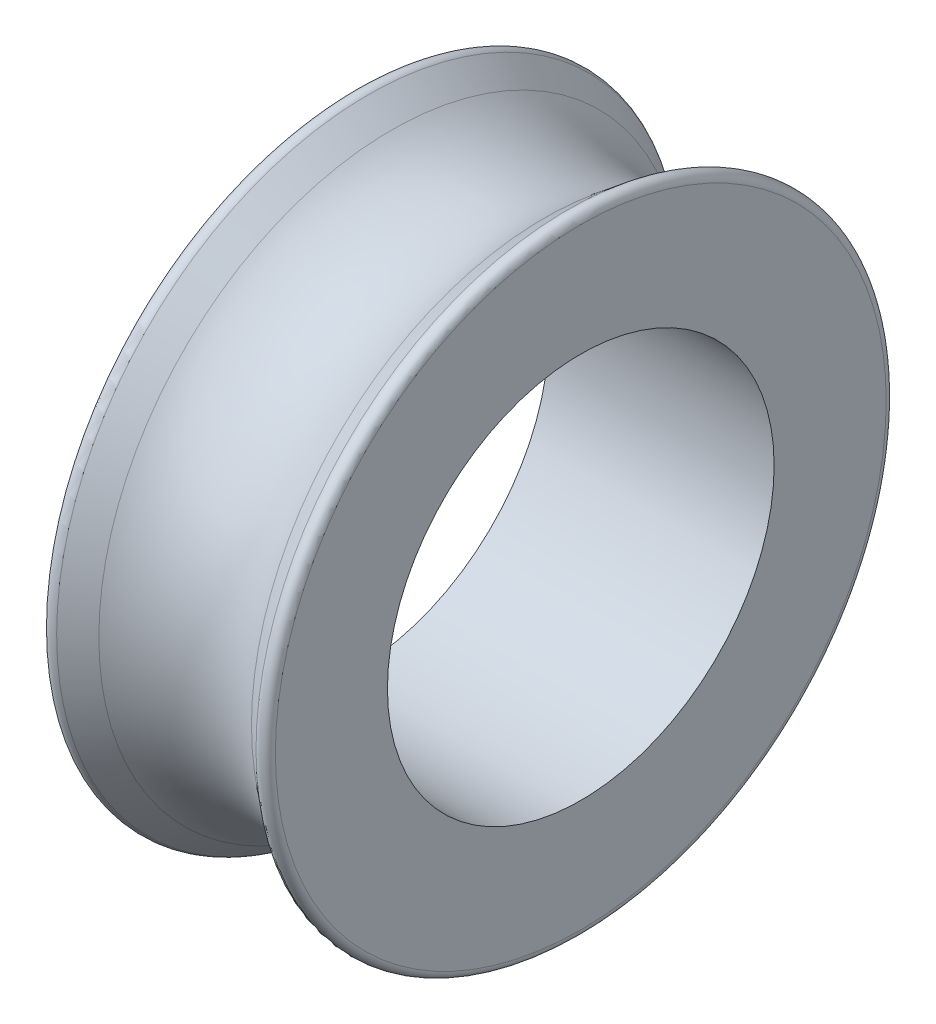
from build123d import *

# Parameters (mm, degrees)
FILLET1_R          = 0.25
CUT_EXTRUDE1_REACH = 9
SKETCH3_R          = 6


with BuildPart() as part:
    # Sketch2 → Revolve1 (revolve)
    with BuildSketch(Plane.XY):
        with BuildLine():
            Line((0, 0), (7, 0))
            Line((7, 0), (7, 10))
            Line((7, 10), (5.868174923, 9.087607037))
            ThreePointArc((5.868174923, 9.087607037), (3.5, 8.251940939), (1.131825077, 9.087607037))
            Line((1.131825077, 9.087607037), (0, 10))
            Line((0, 10), (0, 0))
        make_face()
    revolve(axis=Axis((0, 0, 0), (1, 0, 0)))

    # Fillet1
    fillet1_edges = [part.edges().sort_by_distance(p)[0] for p in [
        (0, -10, 0),
        (7, -10, 0),
    ]]
    fillet(fillet1_edges, radius=FILLET1_R)

    # Sketch3 → Cut-Extrude1 (cut, up to next)
    with BuildSketch(Plane.ZY, mode=Mode.PRIVATE) as cut_extrude1_sk1:
        Circle(SKETCH3_R)
    cut_extrude1_tool1 = extrude(cut_extrude1_sk1.sketch, amount=-CUT_EXTRUDE1_REACH, mode=Mode.PRIVATE) & part.part
    add(cut_extrude1_tool1.solids().sort_by_distance((0, 0, 0))[0], mode=Mode.SUBTRACT)


solid = part.part
